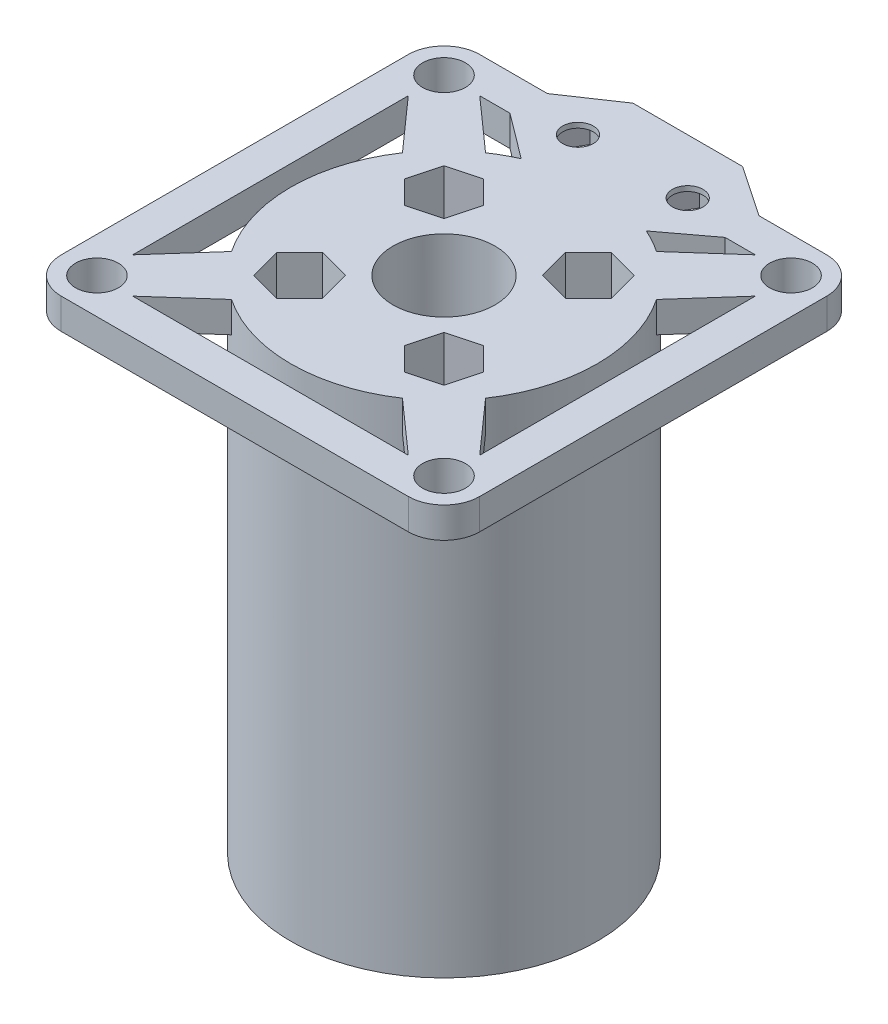
from build123d import *

# Parameters (mm, degrees)
SKETCH_1_R               = 15
SKETCH_1_R_2             = 5
EXTRUDE_4_DEPTH          = 3
SKETCH_1_R_3             = 3.5
SKETCH_1_R_4             = 2.1
EXTRUDE_4_2_DEPTH        = 3
EXTRUDE_5_DEPTH          = 3
PATTERN_CIRCULAR_2_COUNT = 4
SKETCH_6_R               = 3.5
SKETCH_6_R_2             = 2.1
EXTRUDE_6_DEPTH          = 3
PATTERN_CIRCULAR_3_COUNT = 4
SKETCH_7_R               = 15
SKETCH_7_R_2             = 5
EXTRUDE_7_DEPTH          = 46
CUT_EXTRUDE_1_DEPTH      = 46
PATTERN_CIRCULAR_4_COUNT = 4
SKETCH_11_R              = 1.5
CUT_EXTRUDE_2_DEPTH      = 3
PATTERN_CIRCULAR_5_COUNT = 4
EXTRUDE_8_DEPTH          = 3
EXTRUDE_9_DEPTH          = 3
EXTRUDE_10_DEPTH         = 3
EXTRUDE_11_DEPTH         = 3
EXTRUDE_13_DEPTH         = 3
EXTRUDE_14_DEPTH         = 3
CUT_EXTRUDE_3_DEPTH      = 2.5
SKETCH_19_R              = 1.5
CUT_EXTRUDE_4_DEPTH      = 2.5
SKETCH_20_R              = 1.5
CUT_EXTRUDE_5_DEPTH      = 2.5
SKETCH_21_R              = 15
SKETCH_21_R_2            = 5
EXTRUDE_15_DEPTH         = 3
SKETCH_22_R              = 1.5
CUT_EXTRUDE_6_DEPTH      = 3
PATTERN_CIRCULAR_6_COUNT = 4
EXTRUDE_16_DEPTH         = 3
CUT_EXTRUDE_7_DEPTH      = 3
SKETCH_25_R              = 15
SKETCH_25_R_2            = 5
EXTRUDE_17_DEPTH         = 43
SKETCH_27_R              = 1.5
CUT_EXTRUDE_8_DEPTH      = 46
SKETCH_28_R              = 2.75
CUT_EXTRUDE_9_DEPTH      = 43
SKETCH_29_R              = 1.5
CUT_EXTRUDE_10_DEPTH     = 46
PATTERN_CIRCULAR_7_COUNT = 4
CUT_EXTRUDE_11_DEPTH     = 43
PATTERN_CIRCULAR_8_COUNT = 4
SKETCH_31_R              = 29.741034773
CUT_EXTRUDE_12_DEPTH     = 100


with BuildPart() as part:
    # 草图1 → 凸台-拉伸4 (new body)
    with BuildSketch(Plane(origin=(0, 0, 0), x_dir=(1, 0, 0), z_dir=(0, 1, 0))):
        with Locations((-5.372895461, -8.931727747)):
            Circle(SKETCH_1_R)
        with Locations((-5.372895461, -8.931727747)):
            Circle(SKETCH_1_R_2, mode=Mode.SUBTRACT)
    extrude(amount=EXTRUDE_4_DEPTH)



with BuildPart() as body_2:
    # 草图1 → Extrude 4 2 (new body)
    with BuildSketch(Plane(origin=(0, 0, 0), x_dir=(1, 0, 0), z_dir=(0, 1, 0))):
        with Locations((-22.372895461, 8.068272253)):
            Circle(SKETCH_1_R_3)
        with Locations((-22.372895461, 8.068272253)):
            Circle(SKETCH_1_R_4, mode=Mode.SUBTRACT)
    extrude(amount=EXTRUDE_4_2_DEPTH)


with BuildPart() as part_1:
    add(part.part)

    add(body_2.part)  # 凸台-拉伸5 merges body 2
    # 草图5 → 凸台-拉伸5 (add)
    with BuildSketch(Plane(origin=(0, 0, 0), x_dir=(1, 0, 0), z_dir=(0, 1, 0))):
        Polygon((-22.372895461, 4.568272253), (-10.372895461, -8.931727747), (-10.372895461, -3.931727747), (-5.372895461, -3.931727747), (-18.872895461, 8.068272253), align=None)
    extrude_5 = extrude(amount=EXTRUDE_5_DEPTH)

    # 阵列(圆周)2: 凸台-拉伸5 ×4 about axis
    pattern_circular_2_axis = Axis((-5.372895461, 0, 8.931727747), (0, 1, 0))
    for i in range(1, PATTERN_CIRCULAR_2_COUNT):
        add(extrude_5.rotate(pattern_circular_2_axis, i * 360 / PATTERN_CIRCULAR_2_COUNT))

    # 草图6 → 凸台-拉伸6 (add)
    with BuildSketch(Plane(origin=(0, 3, 0), x_dir=(1, 0, 0), z_dir=(0, 1, 0))):
        with Locations((11.627104539, 8.068272253)):
            Circle(SKETCH_6_R)
        with Locations((11.627104539, 8.068272253)):
            Circle(SKETCH_6_R_2, mode=Mode.SUBTRACT)
    extrude_6 = extrude(amount=-EXTRUDE_6_DEPTH)

    # 阵列(圆周)3: 凸台-拉伸6 ×4 about axis
    pattern_circular_3_axis = Axis((-5.372895461, 0, 8.931727747), (0, 1, 0))
    for i in range(1, PATTERN_CIRCULAR_3_COUNT):
        add(extrude_6.rotate(pattern_circular_3_axis, i * 360 / PATTERN_CIRCULAR_3_COUNT))

    # 草图7 → 凸台-拉伸7 (add)
    with BuildSketch(Plane.XZ):
        with Locations((-5.372895461, 8.931727747)):
            Circle(SKETCH_7_R)
        with Locations((-5.372895461, 8.931727747)):
            Circle(SKETCH_7_R_2, mode=Mode.SUBTRACT)
    extrude(amount=EXTRUDE_7_DEPTH)

    # 草图9 → 切除-拉伸1 (cut)
    with BuildSketch(Plane(origin=(0, 3, 0), x_dir=(1, 0, 0), z_dir=(0, 1, 0))):
        Polygon((0.876311502, -19.070022006), (-1.369054096, -16.824656408), (-0.547193246, -13.757429961), (2.520033201, -12.935569112), (4.765398798, -15.180934709), (3.943537949, -18.248161156), align=None)
    cut_extrude_1 = extrude(amount=-CUT_EXTRUDE_1_DEPTH, mode=Mode.SUBTRACT)

    # 阵列(圆周)4: 切除-拉伸1 ×4 about axis
    pattern_circular_4_axis = Axis((-5.372895461, 0, 8.931727747), (0, 1, 0))
    for i in range(1, PATTERN_CIRCULAR_4_COUNT):
        add(cut_extrude_1.rotate(pattern_circular_4_axis, i * 360 / PATTERN_CIRCULAR_4_COUNT), mode=Mode.SUBTRACT)

    # 草图11 → 切除-拉伸2 (cut)
    with BuildSketch(Plane(origin=(0, -43, 0), x_dir=(1, 0, 0), z_dir=(0, 1, 0))):
        with Locations((1.698172351, -1.860659935)):
            Circle(SKETCH_11_R)
    cut_extrude_2 = extrude(amount=-CUT_EXTRUDE_2_DEPTH, mode=Mode.SUBTRACT)

    # 阵列(圆周)5: 切除-拉伸2 ×4 about axis
    pattern_circular_5_axis = Axis((-5.372895461, 0, 8.931727747), (0, 1, 0))
    for i in range(1, PATTERN_CIRCULAR_5_COUNT):
        add(cut_extrude_2.rotate(pattern_circular_5_axis, i * 360 / PATTERN_CIRCULAR_5_COUNT), mode=Mode.SUBTRACT)

    # 草图12 → 凸台-拉伸8 (add)
    with BuildSketch(Plane(origin=(0, 3, 0), x_dir=(1, 0, 0), z_dir=(0, 1, 0))):
        Polygon((15.127104539, 8.068272253), (15.127104539, -25.931727747), (11.627104539, -22.431727747), (11.627104539, 4.568272253), align=None)
    extrude(amount=-EXTRUDE_8_DEPTH)

    # 草图13 → 凸台-拉伸9 (add)
    with BuildSketch(Plane(origin=(0, 3, 0), x_dir=(1, 0, 0), z_dir=(0, 1, 0))):
        Polygon((11.627104539, 11.568272253), (-22.372895461, 11.568272253), (-18.872895461, 8.068272253), (8.127104539, 8.068272253), align=None)
    extrude(amount=-EXTRUDE_9_DEPTH)

    # 草图14 → 凸台-拉伸10 (add)
    with BuildSketch(Plane(origin=(0, 3, 0), x_dir=(1, 0, 0), z_dir=(0, 1, 0))):
        Polygon((-25.872895461, 8.068272253), (-25.872895461, -25.931727747), (-22.372895461, -22.431727747), (-22.372895461, 4.568272253), align=None)
    extrude(amount=-EXTRUDE_10_DEPTH)

    # 草图15 → 凸台-拉伸11 (add)
    with BuildSketch(Plane(origin=(0, 3, 0), x_dir=(1, 0, 0), z_dir=(0, 1, 0))):
        Polygon((-22.372895461, -29.431727747), (11.627104539, -29.431727747), (8.127104539, -25.931727747), (-18.872895461, -25.931727747), align=None)
    extrude(amount=-EXTRUDE_11_DEPTH)

    # 草图16 → 凸台-拉伸13 (add)
    with BuildSketch(Plane.XZ):
        Polygon((-10.747895461, -4.193272253), (0.002104539, -4.193272253), (5.163560245, -8.068272253), (4.99115505, -11.568272253), (0.002104539, -14.943272253), (-10.747895461, -14.943272253), (-15.736945971, -11.568272253), (-15.909351166, -8.068272253), align=None)
        Polygon((-7.57246898, -9.568272253), (-9.16018222, -6.818272253), (-12.335608701, -6.818272253), (-13.923321941, -9.568272253), (-12.335608701, -12.318272253), (-9.16018222, -12.318272253), align=None, mode=Mode.SUBTRACT)
        Polygon((3.17753102, -9.568272253), (1.58981778, -6.818272253), (-1.585608701, -6.818272253), (-3.173321941, -9.568272253), (-1.585608701, -12.318272253), (1.58981778, -12.318272253), align=None, mode=Mode.SUBTRACT)
    extrude(amount=-EXTRUDE_13_DEPTH)

    # 草图18 → 凸台-拉伸14 (add)
    with BuildSketch(Plane.XZ):
        Polygon((-7.57246898, -9.568272253), (-9.16018222, -6.818272253), (-12.335608701, -6.818272253), (-13.923321941, -9.568272253), (-12.335608701, -12.318272253), (-9.16018222, -12.318272253), align=None)
        Polygon((3.17753102, -9.568272253), (1.58981778, -6.818272253), (-1.585608701, -6.818272253), (-3.173321941, -9.568272253), (-1.585608701, -12.318272253), (1.58981778, -12.318272253), align=None)
    extrude(amount=-EXTRUDE_14_DEPTH)

    # 草图17 → 切除-拉伸3 (cut)
    with BuildSketch(Plane.XZ):
        Polygon((-7.57246898, -9.568272253), (-9.16018222, -6.818272253), (-12.335608701, -6.818272253), (-13.923321941, -9.568272253), (-12.335608701, -12.318272253), (-9.16018222, -12.318272253), align=None)
        Polygon((3.17753102, -9.568272253), (1.58981778, -6.818272253), (-1.585608701, -6.818272253), (-3.173321941, -9.568272253), (-1.585608701, -12.318272253), (1.58981778, -12.318272253), align=None)
    extrude(amount=-CUT_EXTRUDE_3_DEPTH, mode=Mode.SUBTRACT)

    # 草图19 → 切除-拉伸4 (cut)
    with BuildSketch(Plane.XZ.offset(-2.5)):
        with Locations((0.002104539, -9.568272253)):
            Circle(SKETCH_19_R)
    extrude(amount=-CUT_EXTRUDE_4_DEPTH, mode=Mode.SUBTRACT)

    # 草图20 → 切除-拉伸5 (cut)
    with BuildSketch(Plane.XZ.offset(-2.5)):
        with Locations((-10.747895461, -9.568272253)):
            Circle(SKETCH_20_R)
    extrude(amount=-CUT_EXTRUDE_5_DEPTH, mode=Mode.SUBTRACT)

    # 草图8 → 凸台-拉伸16 (add)
    with BuildSketch(Plane.XZ.offset(46)):
        Polygon((3.943537949, 18.248161156), (0.876311502, 19.070022006), (-1.369054096, 16.824656408), (-0.547193246, 13.757429961), (2.520033201, 12.935569112), (4.765398798, 15.180934709), align=None)
    extrude(amount=EXTRUDE_16_DEPTH)

    # 草图24 → 切除-拉伸7 (cut)
    with BuildSketch(Plane.XZ.offset(49)):
        Polygon((4.765398798, 15.180934709), (3.943537949, 18.248161156), (0.876311502, 19.070022006), (-1.369054096, 16.824656408), (-0.547193246, 13.757429961), (2.520033201, 12.935569112), align=None)
    extrude(amount=-CUT_EXTRUDE_7_DEPTH, mode=Mode.SUBTRACT)


with BuildPart() as body_2_2:
    # 草图21 → 凸台-拉伸15 (new body)
    with BuildSketch(Plane(origin=(0, 0, 0), x_dir=(1, 0, 0), z_dir=(0, 1, 0))):
        with Locations((59.665545214, -8.931727747)):
            Circle(SKETCH_21_R)
        with Locations((59.665545214, -8.931727747)):
            Circle(SKETCH_21_R_2, mode=Mode.SUBTRACT)
    extrude(amount=EXTRUDE_15_DEPTH)

    # 草图22 → 切除-拉伸6 (cut)
    with BuildSketch(Plane.XZ):
        with Locations((59.665545214, 18.931727747)):
            Circle(SKETCH_22_R)
    cut_extrude_6 = extrude(amount=-CUT_EXTRUDE_6_DEPTH, mode=Mode.SUBTRACT)

    # 阵列(圆周)6: 切除-拉伸6 ×4 about axis
    pattern_circular_6_axis = Axis((59.665545214, 0, 8.931727747), (0, 1, 0))
    for i in range(1, PATTERN_CIRCULAR_6_COUNT):
        add(cut_extrude_6.rotate(pattern_circular_6_axis, i * 360 / PATTERN_CIRCULAR_6_COUNT), mode=Mode.SUBTRACT)

    # 草图25 → 凸台-拉伸17 (add)
    with BuildSketch(Plane.XZ):
        with Locations((59.665545214, 8.931727747)):
            Circle(SKETCH_25_R)
        with Locations((59.665545214, 8.931727747)):
            Circle(SKETCH_25_R_2, mode=Mode.SUBTRACT)
    extrude(amount=EXTRUDE_17_DEPTH)

    # 草图27 → 切除-拉伸8 (cut)
    with BuildSketch(Plane(origin=(0, 3, 0), x_dir=(1, 0, 0), z_dir=(0, 1, 0))):
        with Locations((59.665545214, 1.068272253)):
            Circle(SKETCH_27_R)
        with Locations((69.665545214, -8.931727747)):
            Circle(SKETCH_27_R)
        with Locations((59.665545214, -18.931727747)):
            Circle(SKETCH_27_R)
        with Locations((49.665545214, -8.931727747)):
            Circle(SKETCH_27_R)
    extrude(amount=-CUT_EXTRUDE_8_DEPTH, mode=Mode.SUBTRACT)

    # 草图28 → 切除-拉伸9 (cut)
    with BuildSketch(Plane.XZ.offset(43)):
        with Locations((59.665545214, 18.931727747)):
            Circle(SKETCH_28_R)
        with Locations((49.665545214, 8.931727747)):
            Circle(SKETCH_28_R)
        with Locations((59.665545214, -1.068272253)):
            Circle(SKETCH_28_R)
        with Locations((69.665545214, 8.931727747)):
            Circle(SKETCH_28_R)
    extrude(amount=-CUT_EXTRUDE_9_DEPTH, mode=Mode.SUBTRACT)

    # 草图29 → 切除-拉伸10 (cut)
    with BuildSketch(Plane(origin=(0, 3, 0), x_dir=(1, 0, 0), z_dir=(0, 1, 0))):
        with Locations((66.736613026, -1.860659935)):
            Circle(SKETCH_29_R)
    cut_extrude_10 = extrude(amount=-CUT_EXTRUDE_10_DEPTH, mode=Mode.SUBTRACT)

    # 阵列(圆周)7: 切除-拉伸10 ×4 about axis
    pattern_circular_7_axis = Axis((59.665545214, 0, 8.931727747), (0, 1, 0))
    for i in range(1, PATTERN_CIRCULAR_7_COUNT):
        add(cut_extrude_10.rotate(pattern_circular_7_axis, i * 360 / PATTERN_CIRCULAR_7_COUNT), mode=Mode.SUBTRACT)

    # 草图30 → 切除-拉伸11 (cut)
    with BuildSketch(Plane(origin=(0, 3, 0), x_dir=(1, 0, 0), z_dir=(0, 1, 0))):
        Polygon((64.491247429, -4.106025533), (67.558473876, -4.927886382), (69.803839473, -2.682520785), (68.981978624, 0.384705662), (65.914752177, 1.206566512), (63.669386579, -1.038799086), align=None)
    cut_extrude_11 = extrude(amount=-CUT_EXTRUDE_11_DEPTH, mode=Mode.SUBTRACT)

    # 阵列(圆周)8: 切除-拉伸11 ×4 about axis
    pattern_circular_8_axis = Axis((59.665545214, 0, 8.931727747), (0, 1, 0))
    for i in range(1, PATTERN_CIRCULAR_8_COUNT):
        add(cut_extrude_11.rotate(pattern_circular_8_axis, i * 360 / PATTERN_CIRCULAR_8_COUNT), mode=Mode.SUBTRACT)

    # 草图31 → 切除-拉伸12 (cut)
    with BuildSketch(Plane(origin=(0, 3, 0), x_dir=(1, 0, 0), z_dir=(0, 1, 0))):
        with Locations((59.665545214, -8.931727747)):
            Circle(SKETCH_31_R)
    extrude(amount=-CUT_EXTRUDE_12_DEPTH, mode=Mode.SUBTRACT)


solid = part_1.part
